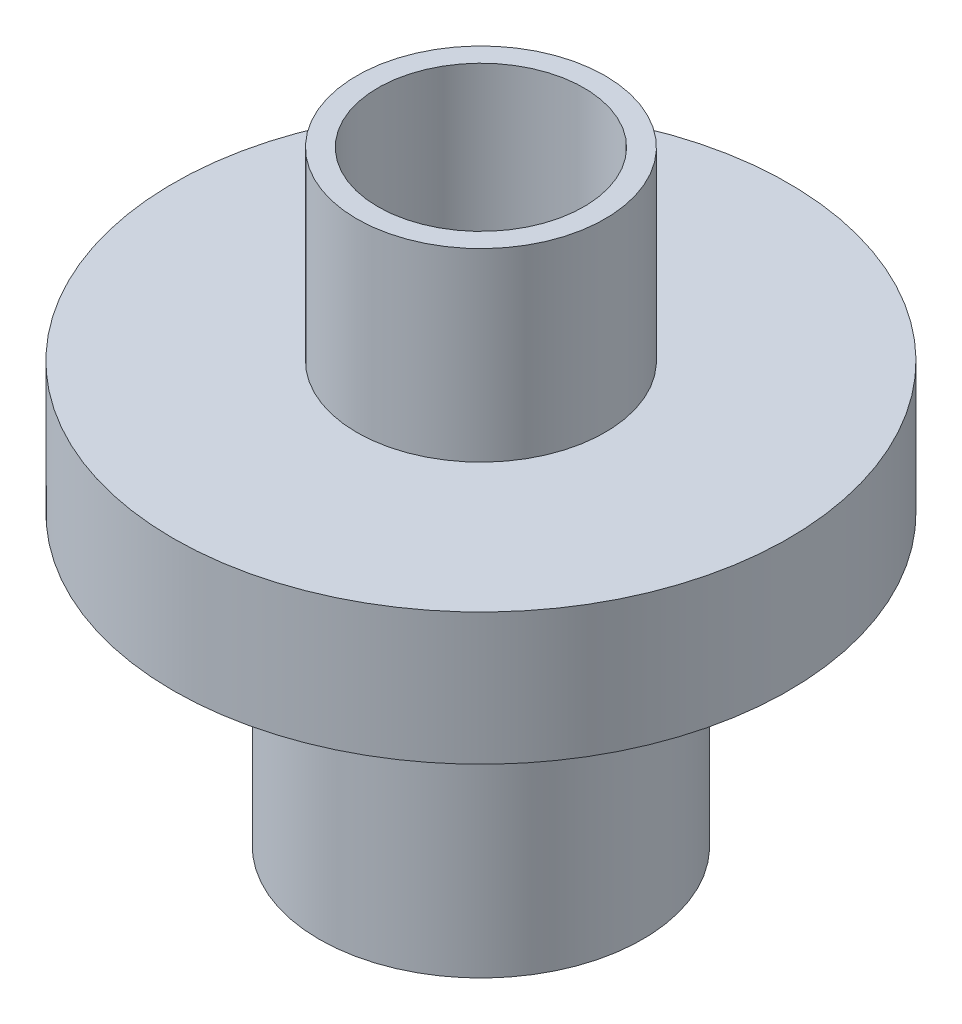
from build123d import *


with BuildPart() as part:
    # Sketch1 → Revolve1 (revolve)
    with BuildSketch(Plane.XY):
        Polygon((-7.4422, 0), (-7.4422, -19.7104), (-10.2108, -19.7104), (-10.2108, -43.7134), (-11.684, -43.7134), (-11.684, -22.8854), (-22.225, -22.8854), (-22.225, -13.3604), (-8.9662, -13.3604), (-8.9662, 0), align=None)
    revolve(axis=Axis((0, 0, 0), (0, -1, 0)))


solid = part.part
